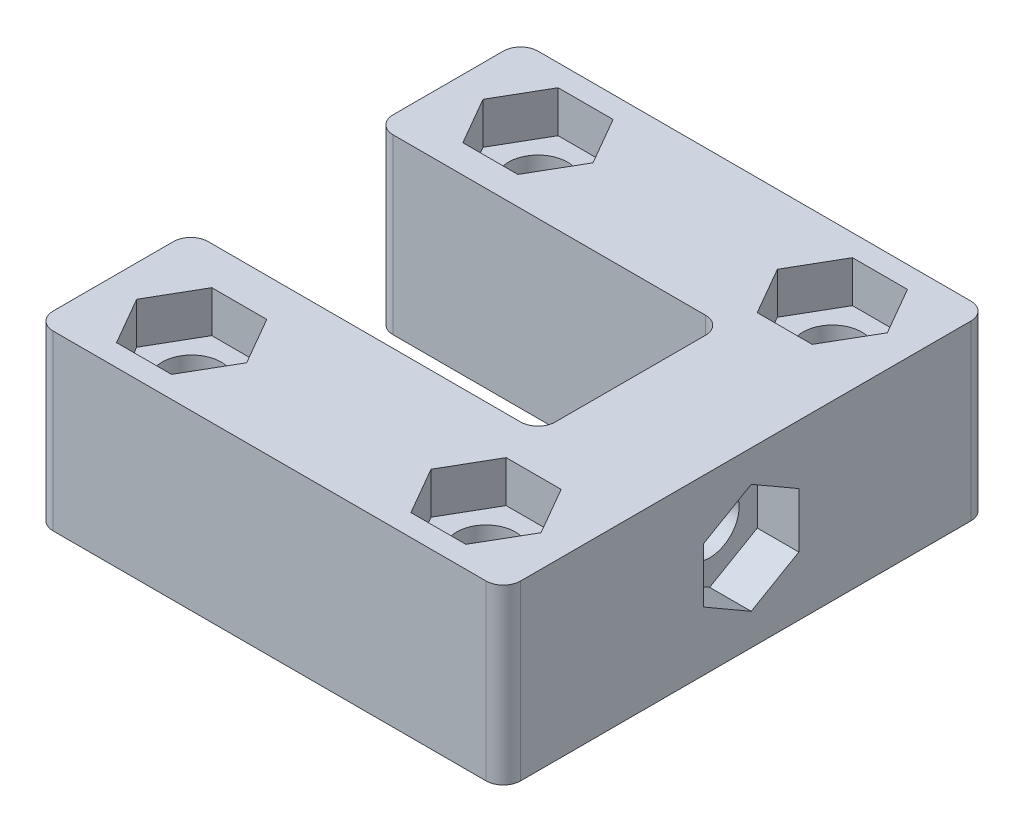
from build123d import *

# Parameters (mm, degrees)
SKETCH1_W            = 27
SKETCH1_H            = 28
BOSS_EXTRUDE1_DEPTH  = 10
SKETCH2_W            = 20.05
SKETCH2_H            = 10.68
CUT_EXTRUDE1_DEPTH   = 11
M3_CLEARANCE_HOLE1_D = 3.4
M3_CLEARANCE_HOLE2_D = 3.4
CUT_EXTRUDE2_DEPTH   = 2.4
FILLET1_R            = 1
CUT_EXTRUDE8_START   = -2.4
CUT_EXTRUDE8_DEPTH   = 2.4


with BuildPart() as part:
    # Sketch1 → Boss-Extrude1 (new body)
    with BuildSketch(Plane(origin=(0, 0, 0), x_dir=(1, 0, 0), z_dir=(0, 1, 0))):
        with Locations((13.5, 14)):
            Rectangle(SKETCH1_W, SKETCH1_H)
    extrude(amount=BOSS_EXTRUDE1_DEPTH)

    # Sketch2 → Cut-Extrude1 (cut, through all)
    with BuildSketch(Plane(origin=(0, 10, 0), x_dir=(1, 0, 0), z_dir=(0, 1, 0))):
        with Locations((10.025, 14.29)):
            Rectangle(SKETCH2_W, SKETCH2_H)
    extrude(amount=-CUT_EXTRUDE1_DEPTH, mode=Mode.SUBTRACT)

    # M3 Clearance Hole1 (through all)
    with Locations(Plane(origin=(27, 0, 0), x_dir=(0, 0, -1), z_dir=(1, 0, 0))):
        with Locations((14.315, 4.999999998)):
            Hole(M3_CLEARANCE_HOLE1_D / 2)

    # M3 Clearance Hole2 (through all)
    with Locations(Plane(origin=(0, 10, 0), x_dir=(1, 0, 0), z_dir=(0, 1, 0))):
        with Locations((5, 24), (22, 24), (22, 4), (5, 4)):
            Hole(M3_CLEARANCE_HOLE2_D / 2)

    # Sketch7 → Cut-Extrude2 (cut)
    with BuildSketch(Plane(origin=(0, 10, 0), x_dir=(1, 0, 0), z_dir=(0, 1, 0))):
        Polygon((6.58771324, 1.25), (8.175426481, 4), (6.58771324, 6.75), (3.41228676, 6.75), (1.824573519, 4), (3.41228676, 1.25), align=None)
        Polygon((23.58771324, 1.25), (25.175426481, 4), (23.58771324, 6.75), (20.41228676, 6.75), (18.824573519, 4), (20.41228676, 1.25), align=None)
        Polygon((23.58771324, 21.25), (25.175426481, 24), (23.58771324, 26.75), (20.41228676, 26.75), (18.824573519, 24), (20.41228676, 21.25), align=None)
        Polygon((6.58771324, 21.25), (8.175426481, 24), (6.58771324, 26.75), (3.41228676, 26.75), (1.824573519, 24), (3.41228676, 21.25), align=None)
    cut_extrude2 = extrude(amount=-CUT_EXTRUDE2_DEPTH, mode=Mode.SUBTRACT)

    # Mirror1: Cut-Extrude2 across plane
    add(cut_extrude2.mirror(Plane.ZX.offset(5)), mode=Mode.SUBTRACT)

    # Fillet1
    fillet1_edges = [part.edges().sort_by_distance(p)[0] for p in [
        (0, 5, -8.95),
        (0, 5, -19.63),
        (20.05, 5, -19.63),
        (20.05, 5, -8.95),
        (0, 5, -28),
        (27, 5, -28),
        (27, 5, 0),
        (0, 5, 0),
    ]]
    fillet(fillet1_edges, radius=FILLET1_R)

    # Sketch12 → Cut-Extrude8 (cut)
    with BuildSketch(Plane(origin=(27, 0, 0), x_dir=(0, 0, -1), z_dir=(1, 0, 0)).offset(CUT_EXTRUDE8_START)):
        Polygon((14.315, 1.824573517), (17.065, 3.412286757), (17.065, 6.587713238), (14.315, 8.175426478), (11.565, 6.587713238), (11.565, 3.412286757), align=None)
    extrude(amount=CUT_EXTRUDE8_DEPTH, mode=Mode.SUBTRACT)


solid = part.part
